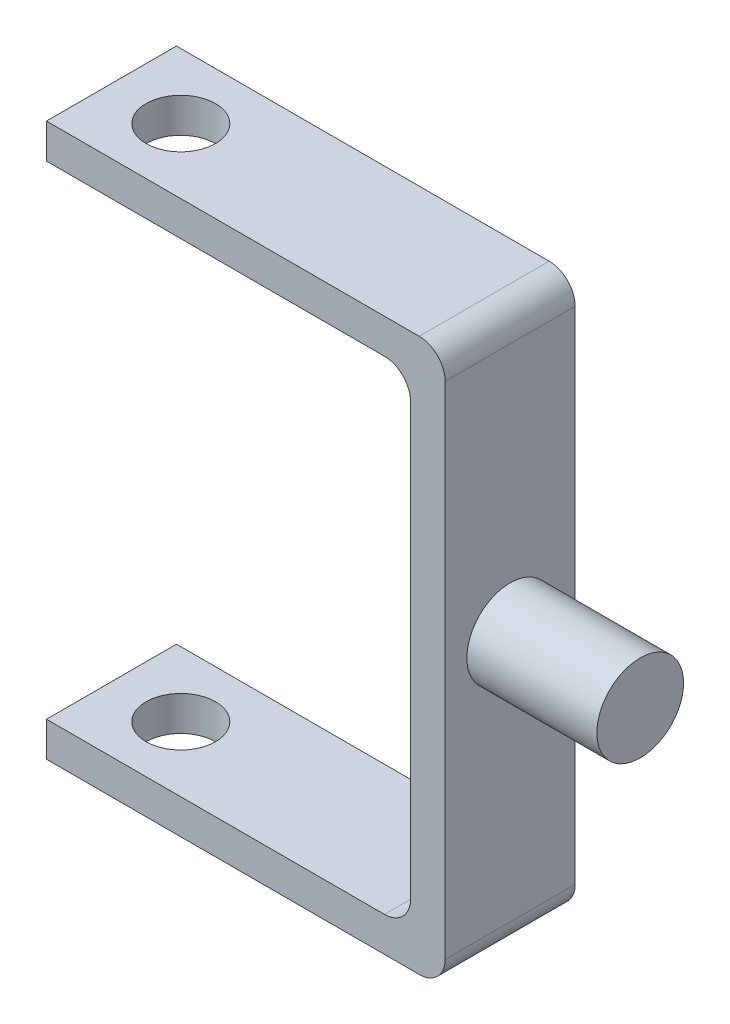
from build123d import *

# Parameters (mm, degrees)
BOSS_EXTRUDE1_DEPTH = 15
SKETCH2_R           = 4
CUT_EXTRUDE1_DEPTH  = 64.763255305
FILLET1_R           = 3
SKETCH4_R           = 5
BOSS_EXTRUDE2_DEPTH = 15
SKETCH5_R           = 3
CUT_EXTRUDE2_DEPTH  = 7


with BuildPart() as part:
    # Sketch1 → Boss-Extrude1 (new body)
    with BuildSketch(Plane.XY):
        Polygon((0, 0), (42, 0), (42, -55.763255305), (0, -55.763255305), (0, -59.763255305), (46, -59.763255305), (46, 4), (0, 4), align=None)
    extrude(amount=BOSS_EXTRUDE1_DEPTH)

    # Sketch2 → Cut-Extrude1 (cut, through all)
    with BuildSketch(Plane(origin=(0, 4, 0), x_dir=(1, 0, 0), z_dir=(0, 1, 0))):
        with Locations((8, -7.5)):
            Circle(SKETCH2_R)
    extrude(amount=-CUT_EXTRUDE1_DEPTH, mode=Mode.SUBTRACT)

    # Fillet1
    fillet1_edges = [part.edges().sort_by_distance(p)[0] for p in [
        (46, 4, 7.5),
        (46, -59.763255305, 7.5),
        (42, -55.763255305, 7.5),
        (42, 0, 7.5),
    ]]
    fillet(fillet1_edges, radius=FILLET1_R)

    # Sketch4 → Boss-Extrude2 (add)
    with BuildSketch(Plane(origin=(46, 0, 0), x_dir=(0, 0, -1), z_dir=(1, 0, 0))):
        with Locations((-7.5, -27.881627652)):
            Circle(SKETCH4_R)
    extrude(amount=BOSS_EXTRUDE2_DEPTH)

    # Sketch5 → Cut-Extrude2 (cut)
    with BuildSketch(Plane.XY):
        with Locations((56, -27.881627652)):
            Circle(SKETCH5_R)
    extrude(amount=CUT_EXTRUDE2_DEPTH, mode=Mode.SUBTRACT)


solid = part.part
